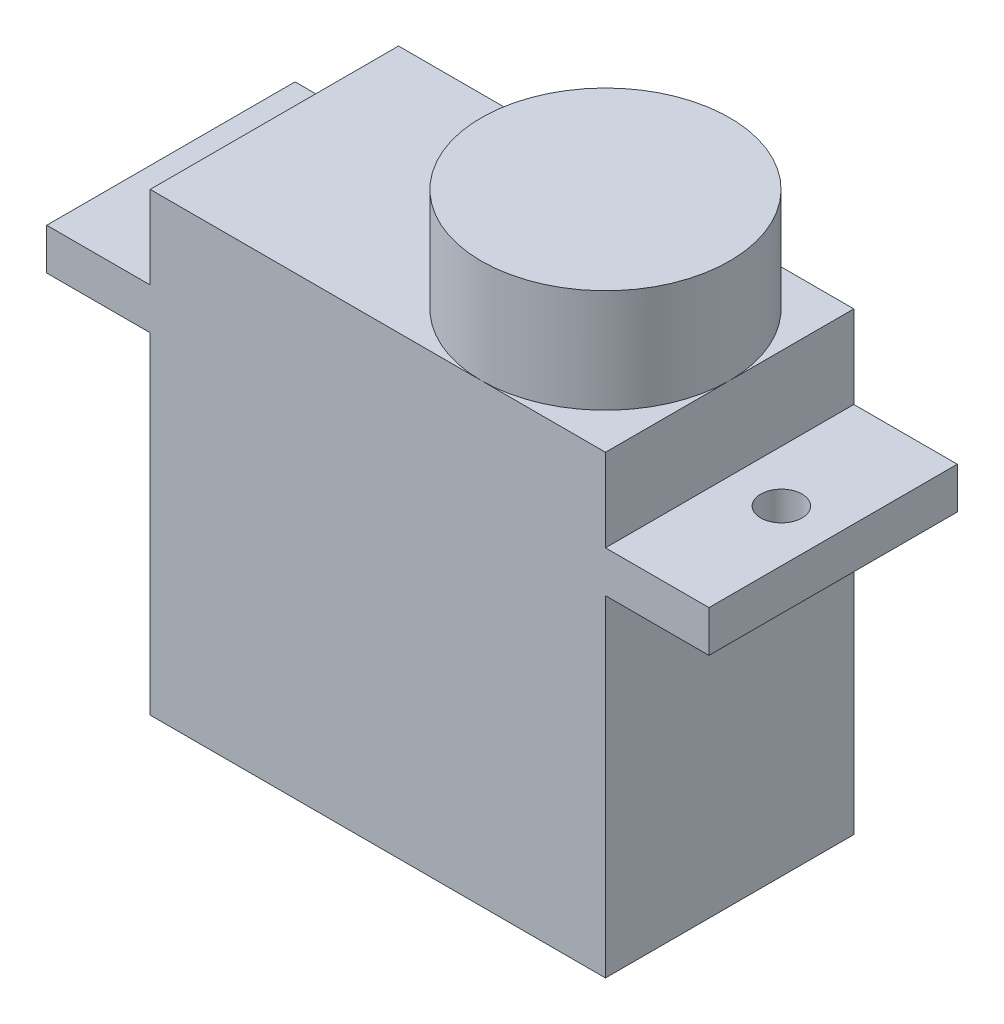
from build123d import *

# Parameters (mm, degrees)
SKETCH1_W           = 22
SKETCH1_H           = 12
BOSS_EXTRUDE1_DEPTH = 22
SKETCH2_W           = 32
SKETCH2_H           = 2
BOSS_EXTRUDE2_DEPTH = 12
SKETCH3_R           = 1
CUT_EXTRUDE1_DEPTH  = 22
SKETCH5_R           = 6
BOSS_EXTRUDE3_DEPTH = 5


with BuildPart() as part:
    # Sketch1 → Boss-Extrude1 (new body)
    with BuildSketch(Plane(origin=(0, 0, 0), x_dir=(1, 0, 0), z_dir=(0, 1, 0))):
        with Locations((11, 6)):
            Rectangle(SKETCH1_W, SKETCH1_H)
    extrude(amount=BOSS_EXTRUDE1_DEPTH)

    # Sketch2 → Boss-Extrude2 (add, through all)
    with BuildSketch(Plane.XY):
        with Locations((11, 17)):
            Rectangle(SKETCH2_W, SKETCH2_H)
    extrude(amount=-BOSS_EXTRUDE2_DEPTH)

    # Sketch3 → Cut-Extrude1 (cut)
    with BuildSketch(Plane(origin=(0, 18, 0), x_dir=(1, 0, 0), z_dir=(0, 1, 0))):
        with Locations((-2.5, 6)):
            Circle(SKETCH3_R)
        with Locations((24.5, 6)):
            Circle(SKETCH3_R)
    extrude(amount=-CUT_EXTRUDE1_DEPTH, mode=Mode.SUBTRACT)

    # Sketch5 → Boss-Extrude3 (add)
    with BuildSketch(Plane(origin=(0, 22, 0), x_dir=(1, 0, 0), z_dir=(0, 1, 0))):
        with Locations((16, 6)):
            Circle(SKETCH5_R)
    extrude(amount=BOSS_EXTRUDE3_DEPTH)


solid = part.part
